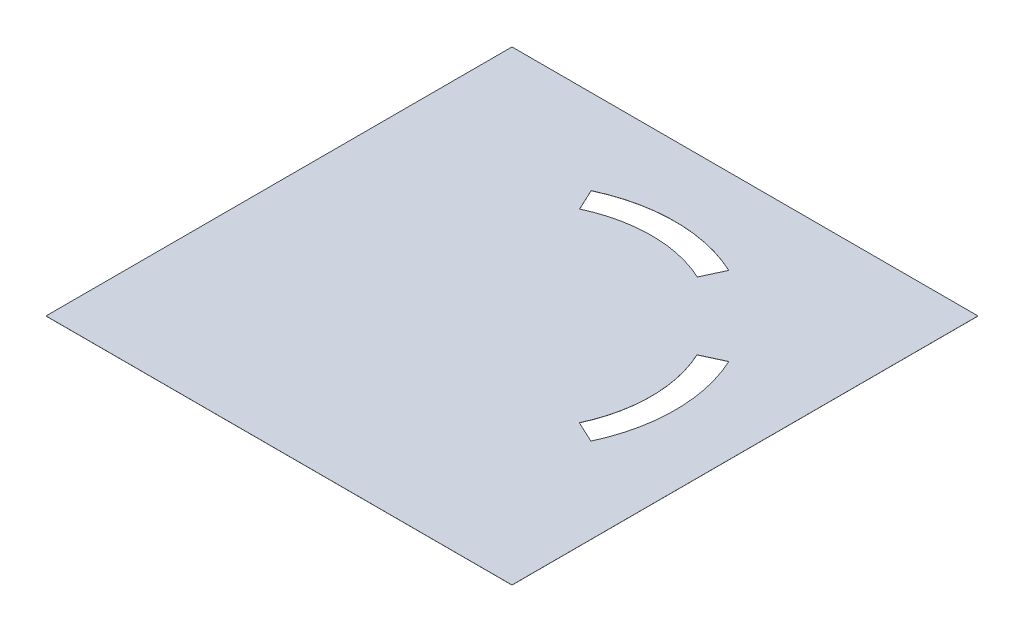
from build123d import *

# Parameters (mm, degrees)
SKETCH1_W           = 107.07
SKETCH1_H           = 107.07
BOSS_EXTRUDE1_DEPTH = 0.02
SCALE2_SCALE        = 0.75


with BuildPart() as part:
    # Sketch1 → Boss-Extrude1 (new body)
    with BuildSketch(Plane(origin=(0, 0, 0), x_dir=(1, 0, 0), z_dir=(0, 1, 0))):
        with Locations((53.535, 53.535)):
            Rectangle(SKETCH1_W, SKETCH1_H)
        with BuildLine():
            Line((40.02098899, 82.576362505), (37.69526755, 87.563888229))
            ThreePointArc((37.69526755, 87.563888229), (53.541760789, 91.075404612), (69.37473245, 87.503415858))
            Line((69.37473245, 87.503415858), (67.077209739, 82.576362505))
            ThreePointArc((67.077209739, 82.576362505), (53.549099365, 85.57547237), (40.02098899, 82.576362505))
        make_face(mode=Mode.SUBTRACT)
        with BuildLine():
            Line((82.518723029, 67.05033201), (87.503415858, 69.37473245))
            ThreePointArc((87.503415858, 69.37473245), (91.015, 53.535), (87.503415858, 37.69526755))
            Line((87.503415858, 37.69526755), (82.518723029, 40.01966799))
            ThreePointArc((82.518723029, 40.01966799), (85.515, 53.535), (82.518723029, 67.05033201))
        make_face(mode=Mode.SUBTRACT)
    extrude(amount=BOSS_EXTRUDE1_DEPTH)


with BuildPart() as part_1:
    # Scale2: scaled about (53.030506877, 0.01, -53.029916686)
    add(part.part.scale(SCALE2_SCALE).moved(Location((13.257626719, 0.0025, -13.257479171))))


solid = part_1.part
